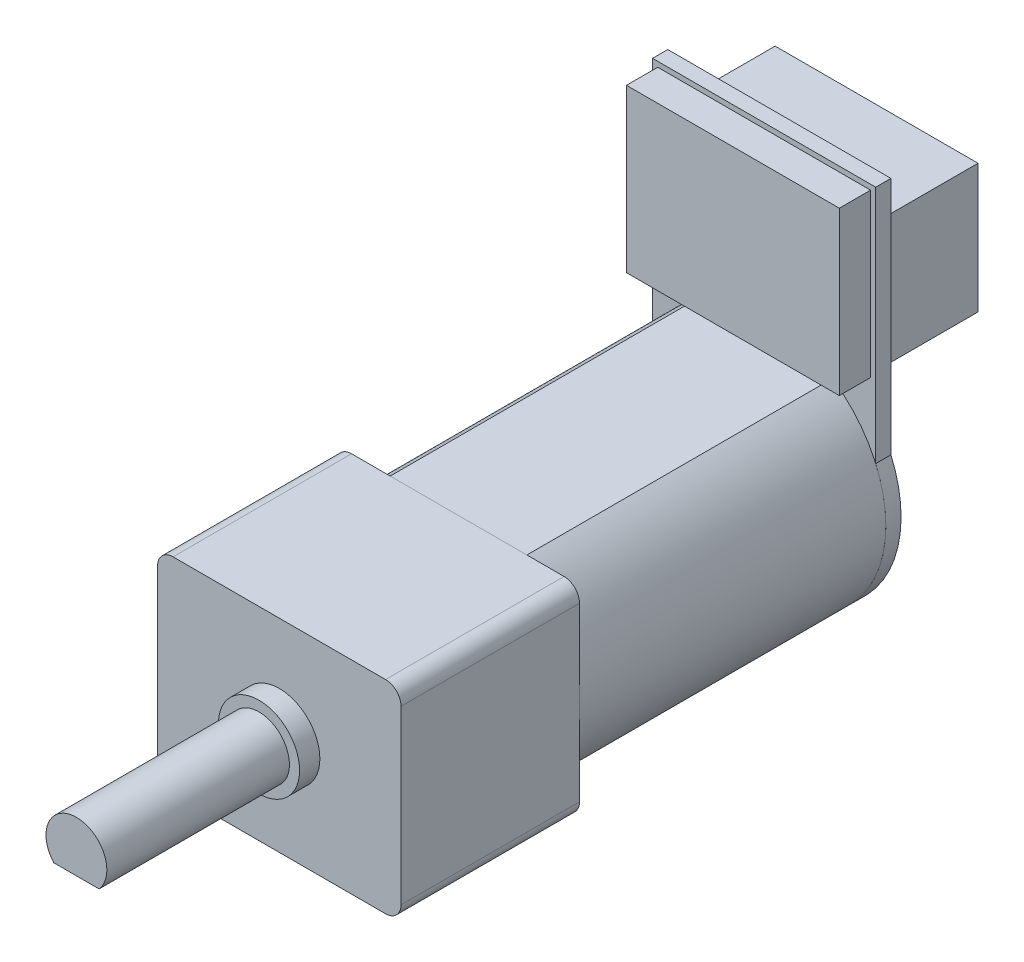
from build123d import *

# Parameters (mm, degrees)
SKETCH1_W           = 12
SKETCH1_H           = 10
BOSS_EXTRUDE1_DEPTH = 8.8
SKETCH2_R           = 2
BOSS_EXTRUDE2_DEPTH = 1
SKETCH3_R           = 1.5
BOSS_EXTRUDE3_DEPTH = 9
CUT_EXTRUDE1_DEPTH  = 8
SKETCH5_R           = 6
BOSS_EXTRUDE4_DEPTH = 15.1
CUT_EXTRUDE2_DEPTH  = 15.1
BOSS_EXTRUDE5_DEPTH = 0.75
SKETCH8_R           = 2
SKETCH8_W           = 0.254
SKETCH8_H           = 2.286
BOSS_EXTRUDE6_DEPTH = 0.5
SKETCH9_W           = 10.492
SKETCH9_H           = 8.001
BOSS_EXTRUDE7_DEPTH = 1.54
SKETCH10_W          = 10
SKETCH10_H          = 6.35
BOSS_EXTRUDE8_DEPTH = 4.792000068
FILLET1_R           = 0.762


with BuildPart() as part:
    # Sketch1 → Boss-Extrude1 (new body)
    with BuildSketch(Plane.XY):
        Rectangle(SKETCH1_W, SKETCH1_H)
    extrude(amount=-BOSS_EXTRUDE1_DEPTH)

    # Sketch2 → Boss-Extrude2 (add)
    with BuildSketch(Plane.XY):
        Circle(SKETCH2_R)
    extrude(amount=BOSS_EXTRUDE2_DEPTH)

    # Sketch3 → Boss-Extrude3 (add)
    with BuildSketch(Plane.XY.offset(1)):
        Circle(SKETCH3_R)
    extrude(amount=BOSS_EXTRUDE3_DEPTH)

    # Sketch4 → Cut-Extrude1 (cut)
    with BuildSketch(Plane.XY.offset(10)):
        with BuildLine():
            Line((1.118033989, -1), (-1.118033989, -1))
            ThreePointArc((-1.118033989, -1), (0, -1.5), (1.118033989, -1))
        make_face()
    extrude(amount=-CUT_EXTRUDE1_DEPTH, mode=Mode.SUBTRACT)

    # Sketch5 → Boss-Extrude4 (add)
    with BuildSketch(Plane(origin=(0, 0, -8.8), x_dir=(-1, 0, 0), z_dir=(0, 0, -1))):
        Circle(SKETCH5_R)
    extrude(amount=BOSS_EXTRUDE4_DEPTH)

    # Sketch6 → Cut-Extrude2 (cut)
    with BuildSketch(Plane(origin=(0, 0, -23.9), x_dir=(-1, 0, 0), z_dir=(0, 0, -1))):
        with BuildLine():
            Line((-3.368794295, 4.965), (3.368794295, 4.965))
            ThreePointArc((3.368794295, 4.965), (0, 6), (-3.368794295, 4.965))
        make_face()
        with BuildLine():
            Line((-3.368794295, -4.965), (3.368794295, -4.965))
            ThreePointArc((3.368794295, -4.965), (0, -6), (-3.368794295, -4.965))
        make_face()
    extrude(amount=-CUT_EXTRUDE2_DEPTH, mode=Mode.SUBTRACT)

    # Fillet1
    fillet1_edges = [part.edges().sort_by_distance(p)[0] for p in [
        (6, -5, -4.4),
        (-6, -5, -4.4),
        (-6, 5, -4.4),
        (6, 5, -4.4),
    ]]
    fillet(fillet1_edges, radius=FILLET1_R)


with BuildPart() as body_2:
    # Sketch7 → Boss-Extrude5 (new body)
    with BuildSketch(Plane(origin=(0, 0, -23.9), x_dir=(-1, 0, 0), z_dir=(0, 0, -1))):
        with BuildLine():
            Line((3.368794295, -4.965), (-3.368794295, -4.965))
            ThreePointArc((-3.368794295, -4.965), (-5.763420008, -1.668229544), (-5.5, 2.397915762))
            Line((-5.5, 2.397915762), (-5.5, 14.2))
            Line((-5.5, 14.2), (5.5, 14.2))
            Line((5.5, 14.2), (5.5, 2.397915762))
            ThreePointArc((5.5, 2.397915762), (5.763420008, -1.668229544), (3.368794295, -4.965))
        make_face()
    extrude(amount=BOSS_EXTRUDE5_DEPTH)

    # Sketch8 → Boss-Extrude6 (add)
    with BuildSketch(Plane(origin=(0, 0, -24.65), x_dir=(-1, 0, 0), z_dir=(0, 0, -1))):
        Circle(SKETCH8_R)
        with Locations((-3.175, 0)):
            Rectangle(SKETCH8_W, SKETCH8_H)
        with Locations((3.175, 0)):
            Rectangle(SKETCH8_W, SKETCH8_H)
    extrude(amount=BOSS_EXTRUDE6_DEPTH)

    # Sketch9 → Boss-Extrude7 (add)
    with BuildSketch(Plane.XY.offset(-23.9)):
        with Locations((0, 9.9455)):
            Rectangle(SKETCH9_W, SKETCH9_H)
    extrude(amount=BOSS_EXTRUDE7_DEPTH)

    # Sketch10 → Boss-Extrude8 (add)
    with BuildSketch(Plane(origin=(0, 0, -24.65), x_dir=(-1, 0, 0), z_dir=(0, 0, -1))):
        with Locations((0, 9.025)):
            Rectangle(SKETCH10_W, SKETCH10_H)
    extrude(amount=BOSS_EXTRUDE8_DEPTH)


solid = Compound([part.part, body_2.part])
